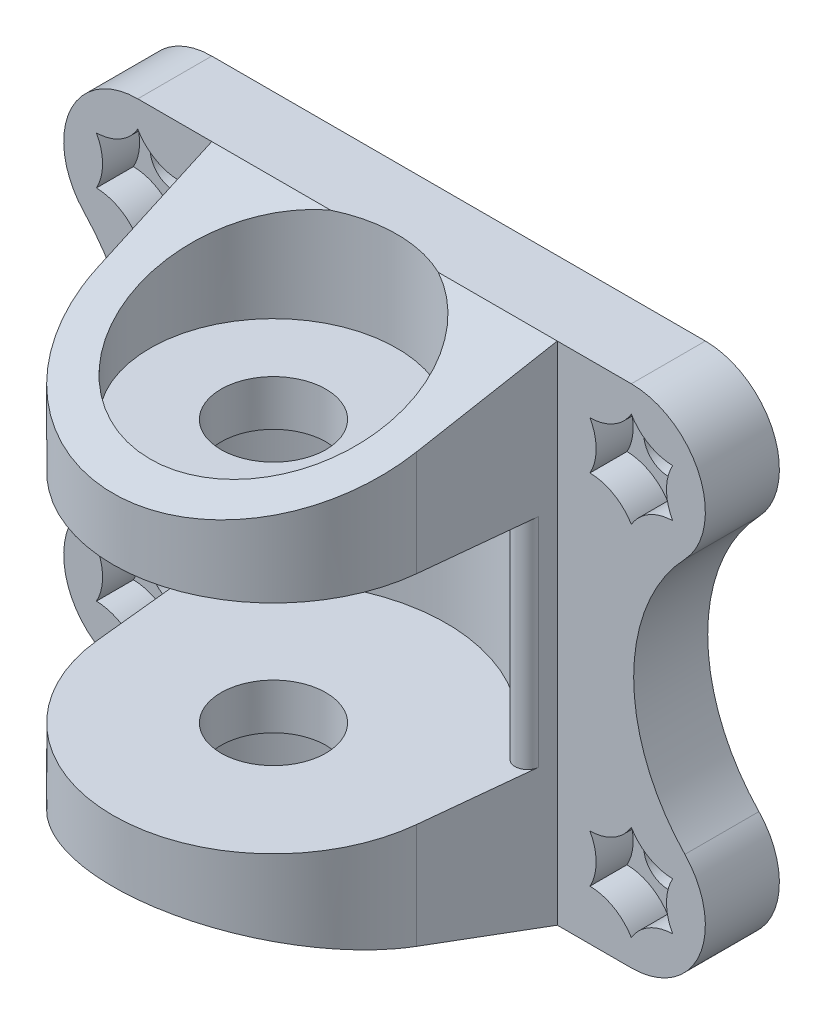
from build123d import *

# Parameters (mm, degrees)
SKETCH1_R            = 4.25
BOSS_EXTRUDE1_DEPTH  = 20.5
SKETCH2_W            = 14
SKETCH2_H            = 17.6
CUT_EXTRUDE1_DEPTH   = 29
SKETCH7_R            = 1
BOSS_EXTRUDE2_DEPTH  = 6
CUT_EXTRUDE6_DEPTH   = 3
SKETCH4_R            = 2
CUT_EXTRUDE2_DEPTH   = 7
SKETCH5_R            = 10
CUT_EXTRUDE3_DEPTH   = 8
SKETCH6_R            = 10
CUT_EXTRUDE4_DEPTH   = 8
FILLET1_R            = 1
CUT_EXTRUDE7_DEPTH   = 3
LPATTERN1_COUNT      = 2
LPATTERN1_PITCH      = 40
LPATTERN1_COUNT_DIR2 = 2
LPATTERN1_PITCH_DIR2 = 29


with BuildPart() as part:
    # Sketch1 → Boss-Extrude1 (new body, symmetric)
    with BuildSketch(Plane(origin=(0, 0, 0), x_dir=(1, 0, 0), z_dir=(0, 1, 0))):
        with BuildLine():
            Line((-12.931045729, -1.337182245), (-14, 9))
            Line((-14, 9), (-14, 15))
            Line((-14, 15), (14, 15))
            Line((14, 15), (14, 9))
            Line((14, 9), (12.931045729, -1.337182245))
            ThreePointArc((12.931045729, -1.337182245), (0, -13), (-12.931045729, -1.337182245))
        make_face()
        with Locations(Location((0, 0, 0), (0, 0, 270))):  # turned: the seam where the file's is
            Circle(SKETCH1_R, mode=Mode.SUBTRACT)
    extrude(amount=BOSS_EXTRUDE1_DEPTH, both=True)

    # Sketch2 → Cut-Revolve1 (revolve, cut)
    with BuildSketch(Plane(origin=(0, 0, 0), x_dir=(0, 0, -1), z_dir=(1, 0, 0))):
        with Locations((-7, 0)):
            Rectangle(SKETCH2_W, SKETCH2_H)
    revolve(axis=Axis((0, 0, 0), (0, 1, 0)), mode=Mode.SUBTRACT)

    # Sketch3 → Cut-Extrude1 (cut, through all)
    with BuildSketch(Plane(origin=(14, 0, 0), x_dir=(0, 0, -1), z_dir=(1, 0, 0))):
        Polygon((9, 20.5), (-13, 13.8), (-13, 20.5), align=None)
        Polygon((-13, -13.8), (9, -20.5), (-13, -20.5), align=None)
    extrude(amount=-CUT_EXTRUDE1_DEPTH, mode=Mode.SUBTRACT)

    # Sketch7 → Boss-Extrude2 (add)
    with BuildSketch(Plane(origin=(0, 0, -15), x_dir=(-1, 0, 0), z_dir=(0, 0, -1))):
        with BuildLine():
            Line((20, 20.5), (14, 20.5))
            Line((14, 20.5), (14, -20.5))
            Line((14, -20.5), (20, -20.5))
            ThreePointArc((20, -20.5), (25.516209879, -16.860387377), (24.340130723, -10.357142857))
            ThreePointArc((24.340130723, -10.357142857), (20.190457531, 0), (24.340130723, 10.357142857))
            ThreePointArc((24.340130723, 10.357142857), (25.516209879, 16.860387377), (20, 20.5))
        make_face()
        with Locations((20, -14.5)):
            Circle(SKETCH7_R, mode=Mode.SUBTRACT)
        with Locations((20, 14.5)):
            Circle(SKETCH7_R, mode=Mode.SUBTRACT)
        with BuildLine():
            Line((-20, -20.5), (-14, -20.5))
            Line((-14, -20.5), (-14, 20.5))
            Line((-14, 20.5), (-20, 20.5))
            ThreePointArc((-20, 20.5), (-25.516209879, 16.860387377), (-24.340130723, 10.357142857))
            ThreePointArc((-24.340130723, 10.357142857), (-20.190457531, 0), (-24.340130723, -10.357142857))
            ThreePointArc((-24.340130723, -10.357142857), (-25.516209879, -16.860387377), (-20, -20.5))
        make_face()
        with Locations((-20, 14.5)):
            Circle(SKETCH7_R, mode=Mode.SUBTRACT)
        with Locations((-20, -14.5)):
            Circle(SKETCH7_R, mode=Mode.SUBTRACT)
    extrude(amount=-BOSS_EXTRUDE2_DEPTH)

    # Sketch8 → Cut-Extrude6 (cut)
    with BuildSketch(Plane.XY.offset(-9)):
        Polygon((-17.15, 12.854551733), (-17.15, 16.145448267), (-20, 17.790896534), (-22.85, 16.145448267), (-22.85, 12.854551733), (-20, 11.209103466), align=None)
        Polygon((-17.15, -12.854551733), (-20, -11.209103466), (-22.85, -12.854551733), (-22.85, -16.145448267), (-20, -17.790896534), (-17.15, -16.145448267), align=None)
        Polygon((22.85, -12.854551733), (20, -11.209103466), (17.15, -12.854551733), (17.15, -16.145448267), (20, -17.790896534), (22.85, -16.145448267), align=None)
        Polygon((22.85, 12.854551733), (22.85, 16.145448267), (20, 17.790896534), (17.15, 16.145448267), (17.15, 12.854551733), (20, 11.209103466), align=None)
    extrude(amount=-CUT_EXTRUDE6_DEPTH, mode=Mode.SUBTRACT)

    # Sketch4 → Cut-Extrude2 (cut)
    with BuildSketch(Plane(origin=(0, 0, -15), x_dir=(-1, 0, 0), z_dir=(0, 0, -1))):
        with Locations((-20, 14.5)):
            Circle(SKETCH4_R)
        with Locations((20, 14.5)):
            Circle(SKETCH4_R)
        with Locations((-20, -14.5)):
            Circle(SKETCH4_R)
        with Locations((20, -14.5)):
            Circle(SKETCH4_R)
    extrude(amount=-CUT_EXTRUDE2_DEPTH, mode=Mode.SUBTRACT)

    # Sketch5 → Cut-Extrude3 (cut)
    with BuildSketch(Plane(origin=(0, 20.5, 0), x_dir=(1, 0, 0), z_dir=(0, 1, 0))):
        with Locations(Location((0, 0, 0), (0, 0, 270))):  # turned: the seam where the file's is
            Circle(SKETCH5_R)
    extrude(amount=-CUT_EXTRUDE3_DEPTH, mode=Mode.SUBTRACT)

    # Sketch6 → Cut-Extrude4 (cut)
    with BuildSketch(Plane.XZ.offset(20.5)):
        with Locations(Location((0, 0, 0), (0, 0, 90))):  # turned: the seam where the file's is
            Circle(SKETCH6_R)
    extrude(amount=-CUT_EXTRUDE4_DEPTH, mode=Mode.SUBTRACT)

    # Fillet1
    fillet1_edges = [part.edges().sort_by_distance(p)[0] for p in [
        (13.465522864, 0, -3.831408877),
        (-13.465522864, 0, -3.831408877),
    ]]
    fillet(fillet1_edges, radius=FILLET1_R)

    # Sketch9 → Cut-Extrude7 (cut)
    with BuildSketch(Plane.XY.offset(-9)):
        with BuildLine():
            ThreePointArc((-23.35, 16.434123402), (-22.85, 14.5), (-23.35, 12.565876598))
            ThreePointArc((-23.35, 12.565876598), (-21.425, 12.031827599), (-20, 10.631753196))
            ThreePointArc((-20, 10.631753196), (-18.575, 12.031827599), (-16.65, 12.565876598))
            ThreePointArc((-16.65, 12.565876598), (-17.15, 14.5), (-16.65, 16.434123402))
            ThreePointArc((-16.65, 16.434123402), (-18.575, 16.968172401), (-20, 18.368246804))
            ThreePointArc((-20, 18.368246804), (-21.425, 16.968172401), (-23.35, 16.434123402))
        make_face()
    cut_extrude7 = extrude(amount=-CUT_EXTRUDE7_DEPTH, mode=Mode.SUBTRACT)

    # LPattern1: Cut-Extrude7 2 × 2
    with Locations(*[(i * LPATTERN1_PITCH, -j * LPATTERN1_PITCH_DIR2, 0) for i in range(LPATTERN1_COUNT) for j in range(LPATTERN1_COUNT_DIR2) if (i, j) != (0, 0)]):
        add(cut_extrude7, mode=Mode.SUBTRACT)


solid = part.part
